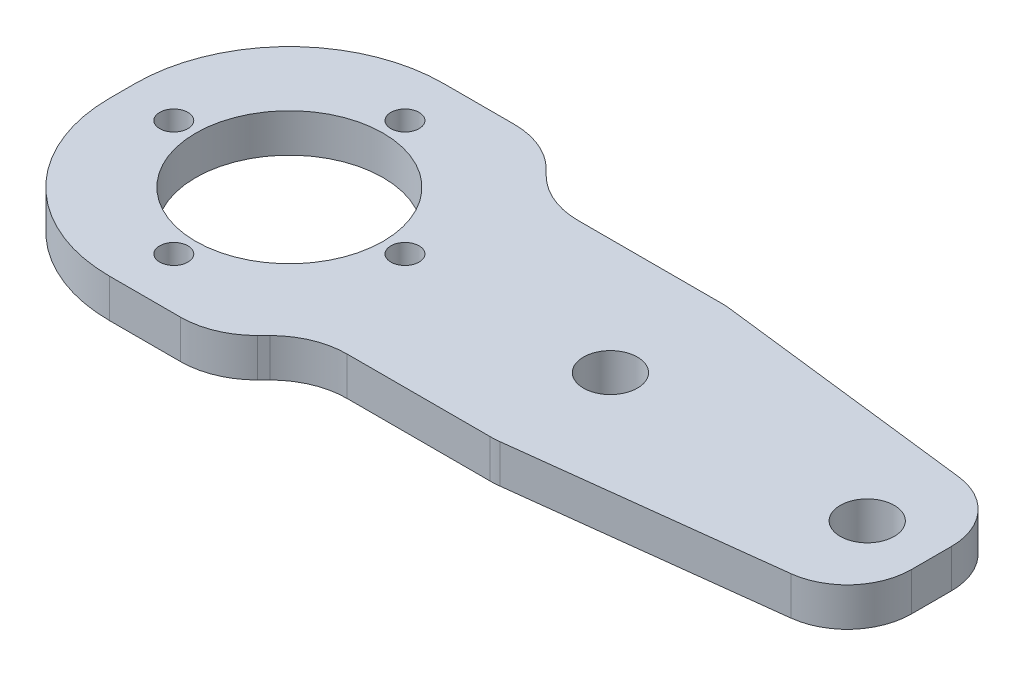
from build123d import *

# Parameters (mm, degrees)
SKETCH1_R           = 7.3
SKETCH1_R_2         = 2.1
BOSS_EXTRUDE1_DEPTH = 3
FILLET1_R           = 12
FILLET4_R           = 6
FILLET5_R           = 5
SKETCH2_R           = 1.1
CUT_EXTRUDE1_DEPTH  = 10


with BuildPart() as part:
    # Sketch1 → Boss-Extrude1 (new body)
    with BuildSketch(Plane(origin=(0, 0, 0), x_dir=(1, 0, 0), z_dir=(0, 1, 0))):
        Polygon((20, 26), (24, 22), (38, 22), (63, 19), (63, 7), (38, 4), (24, 4), (20, 0), (0, 0), (0, 26), align=None)
        with Locations((13, 13)):
            Circle(SKETCH1_R, mode=Mode.SUBTRACT)
        with Locations((38, 13)):
            Circle(SKETCH1_R_2, mode=Mode.SUBTRACT)
        with Locations((58, 13)):
            Circle(SKETCH1_R_2, mode=Mode.SUBTRACT)
    extrude(amount=BOSS_EXTRUDE1_DEPTH)

    # Fillet1
    fillet1_edges = [part.edges().sort_by_distance(p)[0] for p in [
        (0, 1.5, 0),
        (0, 1.5, -26),
    ]]
    fillet(fillet1_edges, radius=FILLET1_R)

    # Fillet4
    fillet4_edges = [part.edges().sort_by_distance(p)[0] for p in [
        (20, 1.5, -26),
        (24, 1.5, -22),
        (38, 1.5, -22),
        (38, 1.5, -4),
        (24, 1.5, -4),
        (20, 1.5, 0),
    ]]
    fillet(fillet4_edges, radius=FILLET4_R)

    # Fillet5
    fillet5_edges = [part.edges().sort_by_distance(p)[0] for p in [
        (63, 1.5, -19),
        (63, 1.5, -7),
    ]]
    fillet(fillet5_edges, radius=FILLET5_R)

    # Sketch2 → Cut-Extrude1 (cut)
    with BuildSketch(Plane(origin=(0, 3, 0), x_dir=(1, 0, 0), z_dir=(0, 1, 0))):
        with Locations((22, 13)):
            Circle(SKETCH2_R)
        with Locations((13, 4)):
            Circle(SKETCH2_R)
        with Locations((4, 13)):
            Circle(SKETCH2_R)
        with Locations((13, 22)):
            Circle(SKETCH2_R)
    extrude(amount=-CUT_EXTRUDE1_DEPTH, mode=Mode.SUBTRACT)


solid = part.part
